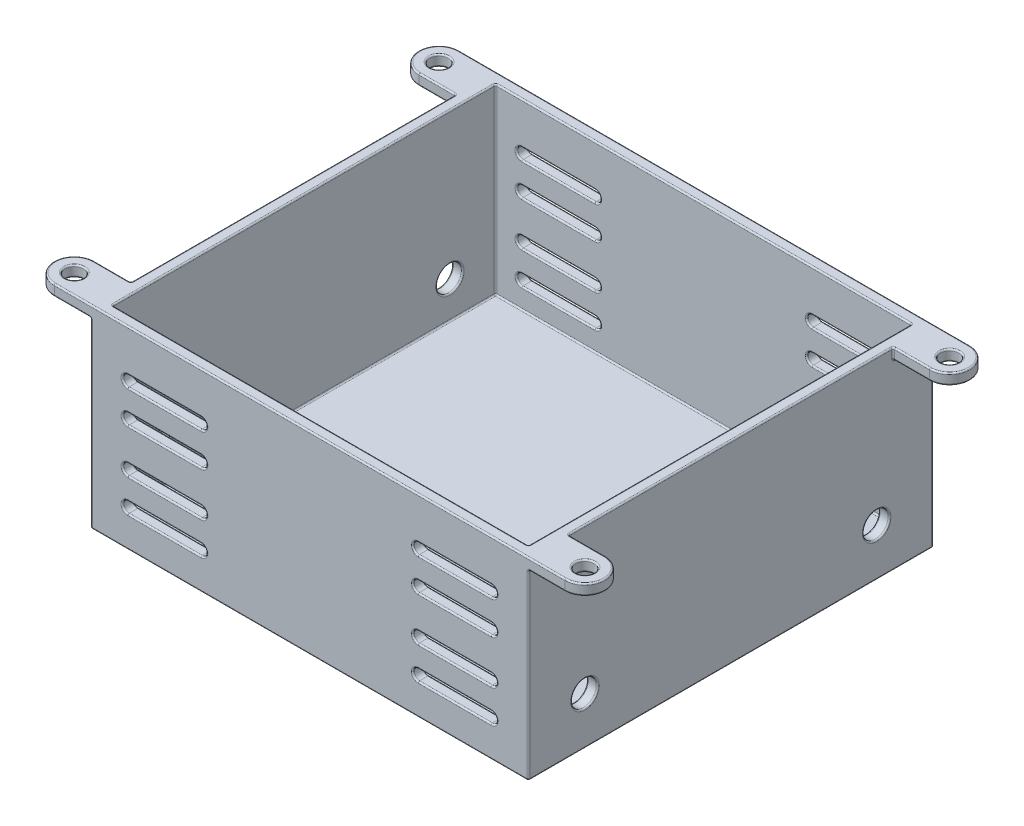
from build123d import *

# Parameters (mm, degrees)
SKETCH9_W                      = 60
SKETCH9_H                      = 55.5
SKETCH9_W_2                    = 57
SKETCH9_H_2                    = 52.5
BOSS_EXTRUDE6_DEPTH            = 25
SKETCH10_W                     = 60
SKETCH10_H                     = 55.5
BOSS_EXTRUDE7_DEPTH            = 1.5
SKETCH11_R                     = 1.25
BOSS_EXTRUDE8_DEPTH            = 1.5
CUT_EXTRUDE1_REACH             = 29.75
CUT_EXTRUDE1_DIRECTION_2_REACH = 29.75
CUT_EXTRUDE2_REACH             = 39.75
SKETCH13_R                     = 1.75
CUT_EXTRUDE2_DIRECTION_2_REACH = 39.75
FILLET1_R                      = 0.2


with BuildPart() as part:
    # Sketch9 → Boss-Extrude6 (new body)
    with BuildSketch(Plane(origin=(0, 0, 0), x_dir=(1, 0, 0), z_dir=(0, 1, 0))):
        Rectangle(SKETCH9_W, SKETCH9_H)
        Rectangle(SKETCH9_W_2, SKETCH9_H_2, mode=Mode.SUBTRACT)
    extrude(amount=-BOSS_EXTRUDE6_DEPTH)

    # Sketch10 → Boss-Extrude7 (add)
    with BuildSketch(Plane.XZ.offset(25)):
        Rectangle(SKETCH10_W, SKETCH10_H)
    extrude(amount=BOSS_EXTRUDE7_DEPTH)

    # Sketch11 → Boss-Extrude8 (add)
    with BuildSketch(Plane(origin=(0, 0, 0), x_dir=(1, 0, 0), z_dir=(0, 1, 0))):
        with BuildLine():
            Line((35, -27.75), (30, -27.75))
            Line((30, -27.75), (30, -22.25))
            Line((30, -22.25), (35, -22.25))
            ThreePointArc((35, -22.25), (37.75, -25), (35, -27.75))
        make_face()
        with Locations((35, -25)):
            Circle(SKETCH11_R, mode=Mode.SUBTRACT)
        with BuildLine():
            Line((-35, 27.75), (-30, 27.75))
            Line((-30, 27.75), (-30, 22.25))
            Line((-30, 22.25), (-35, 22.25))
            ThreePointArc((-35, 22.25), (-37.75, 25), (-35, 27.75))
        make_face()
        with Locations((-35, 25)):
            Circle(SKETCH11_R, mode=Mode.SUBTRACT)
        with BuildLine():
            Line((-35, -22.25), (-30, -22.25))
            Line((-30, -22.25), (-30, -27.75))
            Line((-30, -27.75), (-35, -27.75))
            ThreePointArc((-35, -27.75), (-37.75, -25), (-35, -22.25))
        make_face()
        with Locations((-35, -25)):
            Circle(SKETCH11_R, mode=Mode.SUBTRACT)
        with BuildLine():
            Line((35, 22.25), (30, 22.25))
            Line((30, 22.25), (30, 27.75))
            Line((30, 27.75), (35, 27.75))
            ThreePointArc((35, 27.75), (37.75, 25), (35, 22.25))
        make_face()
        with Locations((35, 25)):
            Circle(SKETCH11_R, mode=Mode.SUBTRACT)
    extrude(amount=-BOSS_EXTRUDE8_DEPTH)

    # Cut-Extrude1: up to this face of the body (flat: up to its plane)
    cut_extrude1_end = Plane(part.part.faces().sort_by_distance((0, -13.13317757, -27.75))[0])
    # Sketch12 → Cut-Extrude1 (cut, up to the picked face)
    with BuildSketch(Plane.XY, mode=Mode.PRIVATE) as cut_extrude1_sk1:
        with BuildLine():
            Line((-24.896270591, -5.75), (-14.896270591, -5.75))
            ThreePointArc((-14.896270591, -5.75), (-14.146270591, -6.5), (-14.896270591, -7.25))
            Line((-14.896270591, -7.25), (-24.896270591, -7.25))
            ThreePointArc((-24.896270591, -7.25), (-25.646270591, -6.5), (-24.896270591, -5.75))
        make_face()
    cut_extrude1_tool1 = split(extrude(cut_extrude1_sk1.sketch, amount=-CUT_EXTRUDE1_REACH, mode=Mode.PRIVATE), bisect_by=cut_extrude1_end, keep=Keep.BOTH, mode=Mode.PRIVATE)
    add(cut_extrude1_tool1.solids().sort_by_distance((-19.896271, -6.5, 0))[0], mode=Mode.SUBTRACT)
    # Sketch12 → Cut-Extrude1 (cut, up to the picked face)
    with BuildSketch(Plane.XY, mode=Mode.PRIVATE) as cut_extrude1_sk2:
        with BuildLine():
            Line((-24.896270591, -10.25), (-14.896270591, -10.25))
            ThreePointArc((-14.896270591, -10.25), (-14.146270591, -11), (-14.896270591, -11.75))
            Line((-14.896270591, -11.75), (-24.896270591, -11.75))
            ThreePointArc((-24.896270591, -11.75), (-25.646270591, -11), (-24.896270591, -10.25))
        make_face()
    cut_extrude1_tool2 = split(extrude(cut_extrude1_sk2.sketch, amount=-CUT_EXTRUDE1_REACH, mode=Mode.PRIVATE), bisect_by=cut_extrude1_end, keep=Keep.BOTH, mode=Mode.PRIVATE)
    add(cut_extrude1_tool2.solids().sort_by_distance((-19.896271, -11, 0))[0], mode=Mode.SUBTRACT)
    # Sketch12 → Cut-Extrude1 (cut, up to the picked face)
    with BuildSketch(Plane.XY, mode=Mode.PRIVATE) as cut_extrude1_sk3:
        with BuildLine():
            Line((-24.896270591, -17.75), (-14.896270591, -17.75))
            ThreePointArc((-14.896270591, -17.75), (-14.146270591, -17), (-14.896270591, -16.25))
            Line((-14.896270591, -16.25), (-24.896270591, -16.25))
            ThreePointArc((-24.896270591, -16.25), (-25.646270591, -17), (-24.896270591, -17.75))
        make_face()
    cut_extrude1_tool3 = split(extrude(cut_extrude1_sk3.sketch, amount=-CUT_EXTRUDE1_REACH, mode=Mode.PRIVATE), bisect_by=cut_extrude1_end, keep=Keep.BOTH, mode=Mode.PRIVATE)
    add(cut_extrude1_tool3.solids().sort_by_distance((-19.896271, -17, 0))[0], mode=Mode.SUBTRACT)
    # Sketch12 → Cut-Extrude1 (cut, up to the picked face)
    with BuildSketch(Plane.XY, mode=Mode.PRIVATE) as cut_extrude1_sk4:
        with BuildLine():
            Line((-24.896270591, -22.25), (-14.896270591, -22.25))
            ThreePointArc((-14.896270591, -22.25), (-14.146270591, -21.5), (-14.896270591, -20.75))
            Line((-14.896270591, -20.75), (-24.896270591, -20.75))
            ThreePointArc((-24.896270591, -20.75), (-25.646270591, -21.5), (-24.896270591, -22.25))
        make_face()
    cut_extrude1_tool4 = split(extrude(cut_extrude1_sk4.sketch, amount=-CUT_EXTRUDE1_REACH, mode=Mode.PRIVATE), bisect_by=cut_extrude1_end, keep=Keep.BOTH, mode=Mode.PRIVATE)
    add(cut_extrude1_tool4.solids().sort_by_distance((-19.896271, -21.5, 0))[0], mode=Mode.SUBTRACT)
    # Sketch12 → Cut-Extrude1 (cut, up to the picked face)
    with BuildSketch(Plane.XY, mode=Mode.PRIVATE) as cut_extrude1_sk5:
        with BuildLine():
            Line((24.896270591, -22.25), (14.896270591, -22.25))
            ThreePointArc((14.896270591, -22.25), (14.146270591, -21.5), (14.896270591, -20.75))
            Line((14.896270591, -20.75), (24.896270591, -20.75))
            ThreePointArc((24.896270591, -20.75), (25.646270591, -21.5), (24.896270591, -22.25))
        make_face()
    cut_extrude1_tool5 = split(extrude(cut_extrude1_sk5.sketch, amount=-CUT_EXTRUDE1_REACH, mode=Mode.PRIVATE), bisect_by=cut_extrude1_end, keep=Keep.BOTH, mode=Mode.PRIVATE)
    add(cut_extrude1_tool5.solids().sort_by_distance((19.896271, -21.5, 0))[0], mode=Mode.SUBTRACT)
    # Sketch12 → Cut-Extrude1 (cut, up to the picked face)
    with BuildSketch(Plane.XY, mode=Mode.PRIVATE) as cut_extrude1_sk6:
        with BuildLine():
            Line((24.896270591, -17.75), (14.896270591, -17.75))
            ThreePointArc((14.896270591, -17.75), (14.146270591, -17), (14.896270591, -16.25))
            Line((14.896270591, -16.25), (24.896270591, -16.25))
            ThreePointArc((24.896270591, -16.25), (25.646270591, -17), (24.896270591, -17.75))
        make_face()
    cut_extrude1_tool6 = split(extrude(cut_extrude1_sk6.sketch, amount=-CUT_EXTRUDE1_REACH, mode=Mode.PRIVATE), bisect_by=cut_extrude1_end, keep=Keep.BOTH, mode=Mode.PRIVATE)
    add(cut_extrude1_tool6.solids().sort_by_distance((19.896271, -17, 0))[0], mode=Mode.SUBTRACT)
    # Sketch12 → Cut-Extrude1 (cut, up to the picked face)
    with BuildSketch(Plane.XY, mode=Mode.PRIVATE) as cut_extrude1_sk7:
        with BuildLine():
            Line((24.896270591, -10.25), (14.896270591, -10.25))
            ThreePointArc((14.896270591, -10.25), (14.146270591, -11), (14.896270591, -11.75))
            Line((14.896270591, -11.75), (24.896270591, -11.75))
            ThreePointArc((24.896270591, -11.75), (25.646270591, -11), (24.896270591, -10.25))
        make_face()
    cut_extrude1_tool7 = split(extrude(cut_extrude1_sk7.sketch, amount=-CUT_EXTRUDE1_REACH, mode=Mode.PRIVATE), bisect_by=cut_extrude1_end, keep=Keep.BOTH, mode=Mode.PRIVATE)
    add(cut_extrude1_tool7.solids().sort_by_distance((19.896271, -11, 0))[0], mode=Mode.SUBTRACT)
    # Sketch12 → Cut-Extrude1 (cut, up to the picked face)
    with BuildSketch(Plane.XY, mode=Mode.PRIVATE) as cut_extrude1_sk8:
        with BuildLine():
            Line((24.896270591, -5.75), (14.896270591, -5.75))
            ThreePointArc((14.896270591, -5.75), (14.146270591, -6.5), (14.896270591, -7.25))
            Line((14.896270591, -7.25), (24.896270591, -7.25))
            ThreePointArc((24.896270591, -7.25), (25.646270591, -6.5), (24.896270591, -5.75))
        make_face()
    cut_extrude1_tool8 = split(extrude(cut_extrude1_sk8.sketch, amount=-CUT_EXTRUDE1_REACH, mode=Mode.PRIVATE), bisect_by=cut_extrude1_end, keep=Keep.BOTH, mode=Mode.PRIVATE)
    add(cut_extrude1_tool8.solids().sort_by_distance((19.896271, -6.5, 0))[0], mode=Mode.SUBTRACT)

    # Cut-Extrude1 direction 2: up to this face of the body (flat: up to its plane)
    cut_extrude1_direction_2_end = Plane(part.part.faces().sort_by_distance((0, -13.13317757, 27.75))[0])
    # Sketch12 → Cut-Extrude1 direction 2 (cut, up to the picked face)
    with BuildSketch(Plane.XY, mode=Mode.PRIVATE) as cut_extrude1_direction_2_sk1:
        with BuildLine():
            Line((-24.896270591, -5.75), (-14.896270591, -5.75))
            ThreePointArc((-14.896270591, -5.75), (-14.146270591, -6.5), (-14.896270591, -7.25))
            Line((-14.896270591, -7.25), (-24.896270591, -7.25))
            ThreePointArc((-24.896270591, -7.25), (-25.646270591, -6.5), (-24.896270591, -5.75))
        make_face()
    cut_extrude1_direction_2_tool1 = split(extrude(cut_extrude1_direction_2_sk1.sketch, amount=CUT_EXTRUDE1_DIRECTION_2_REACH, mode=Mode.PRIVATE), bisect_by=cut_extrude1_direction_2_end, keep=Keep.BOTH, mode=Mode.PRIVATE)
    add(cut_extrude1_direction_2_tool1.solids().sort_by_distance((-19.896271, -6.5, 0))[0], mode=Mode.SUBTRACT)
    # Sketch12 → Cut-Extrude1 direction 2 (cut, up to the picked face)
    with BuildSketch(Plane.XY, mode=Mode.PRIVATE) as cut_extrude1_direction_2_sk2:
        with BuildLine():
            Line((-24.896270591, -10.25), (-14.896270591, -10.25))
            ThreePointArc((-14.896270591, -10.25), (-14.146270591, -11), (-14.896270591, -11.75))
            Line((-14.896270591, -11.75), (-24.896270591, -11.75))
            ThreePointArc((-24.896270591, -11.75), (-25.646270591, -11), (-24.896270591, -10.25))
        make_face()
    cut_extrude1_direction_2_tool2 = split(extrude(cut_extrude1_direction_2_sk2.sketch, amount=CUT_EXTRUDE1_DIRECTION_2_REACH, mode=Mode.PRIVATE), bisect_by=cut_extrude1_direction_2_end, keep=Keep.BOTH, mode=Mode.PRIVATE)
    add(cut_extrude1_direction_2_tool2.solids().sort_by_distance((-19.896271, -11, 0))[0], mode=Mode.SUBTRACT)
    # Sketch12 → Cut-Extrude1 direction 2 (cut, up to the picked face)
    with BuildSketch(Plane.XY, mode=Mode.PRIVATE) as cut_extrude1_direction_2_sk3:
        with BuildLine():
            Line((-24.896270591, -17.75), (-14.896270591, -17.75))
            ThreePointArc((-14.896270591, -17.75), (-14.146270591, -17), (-14.896270591, -16.25))
            Line((-14.896270591, -16.25), (-24.896270591, -16.25))
            ThreePointArc((-24.896270591, -16.25), (-25.646270591, -17), (-24.896270591, -17.75))
        make_face()
    cut_extrude1_direction_2_tool3 = split(extrude(cut_extrude1_direction_2_sk3.sketch, amount=CUT_EXTRUDE1_DIRECTION_2_REACH, mode=Mode.PRIVATE), bisect_by=cut_extrude1_direction_2_end, keep=Keep.BOTH, mode=Mode.PRIVATE)
    add(cut_extrude1_direction_2_tool3.solids().sort_by_distance((-19.896271, -17, 0))[0], mode=Mode.SUBTRACT)
    # Sketch12 → Cut-Extrude1 direction 2 (cut, up to the picked face)
    with BuildSketch(Plane.XY, mode=Mode.PRIVATE) as cut_extrude1_direction_2_sk4:
        with BuildLine():
            Line((-24.896270591, -22.25), (-14.896270591, -22.25))
            ThreePointArc((-14.896270591, -22.25), (-14.146270591, -21.5), (-14.896270591, -20.75))
            Line((-14.896270591, -20.75), (-24.896270591, -20.75))
            ThreePointArc((-24.896270591, -20.75), (-25.646270591, -21.5), (-24.896270591, -22.25))
        make_face()
    cut_extrude1_direction_2_tool4 = split(extrude(cut_extrude1_direction_2_sk4.sketch, amount=CUT_EXTRUDE1_DIRECTION_2_REACH, mode=Mode.PRIVATE), bisect_by=cut_extrude1_direction_2_end, keep=Keep.BOTH, mode=Mode.PRIVATE)
    add(cut_extrude1_direction_2_tool4.solids().sort_by_distance((-19.896271, -21.5, 0))[0], mode=Mode.SUBTRACT)
    # Sketch12 → Cut-Extrude1 direction 2 (cut, up to the picked face)
    with BuildSketch(Plane.XY, mode=Mode.PRIVATE) as cut_extrude1_direction_2_sk5:
        with BuildLine():
            Line((24.896270591, -22.25), (14.896270591, -22.25))
            ThreePointArc((14.896270591, -22.25), (14.146270591, -21.5), (14.896270591, -20.75))
            Line((14.896270591, -20.75), (24.896270591, -20.75))
            ThreePointArc((24.896270591, -20.75), (25.646270591, -21.5), (24.896270591, -22.25))
        make_face()
    cut_extrude1_direction_2_tool5 = split(extrude(cut_extrude1_direction_2_sk5.sketch, amount=CUT_EXTRUDE1_DIRECTION_2_REACH, mode=Mode.PRIVATE), bisect_by=cut_extrude1_direction_2_end, keep=Keep.BOTH, mode=Mode.PRIVATE)
    add(cut_extrude1_direction_2_tool5.solids().sort_by_distance((19.896271, -21.5, 0))[0], mode=Mode.SUBTRACT)
    # Sketch12 → Cut-Extrude1 direction 2 (cut, up to the picked face)
    with BuildSketch(Plane.XY, mode=Mode.PRIVATE) as cut_extrude1_direction_2_sk6:
        with BuildLine():
            Line((24.896270591, -17.75), (14.896270591, -17.75))
            ThreePointArc((14.896270591, -17.75), (14.146270591, -17), (14.896270591, -16.25))
            Line((14.896270591, -16.25), (24.896270591, -16.25))
            ThreePointArc((24.896270591, -16.25), (25.646270591, -17), (24.896270591, -17.75))
        make_face()
    cut_extrude1_direction_2_tool6 = split(extrude(cut_extrude1_direction_2_sk6.sketch, amount=CUT_EXTRUDE1_DIRECTION_2_REACH, mode=Mode.PRIVATE), bisect_by=cut_extrude1_direction_2_end, keep=Keep.BOTH, mode=Mode.PRIVATE)
    add(cut_extrude1_direction_2_tool6.solids().sort_by_distance((19.896271, -17, 0))[0], mode=Mode.SUBTRACT)
    # Sketch12 → Cut-Extrude1 direction 2 (cut, up to the picked face)
    with BuildSketch(Plane.XY, mode=Mode.PRIVATE) as cut_extrude1_direction_2_sk7:
        with BuildLine():
            Line((24.896270591, -10.25), (14.896270591, -10.25))
            ThreePointArc((14.896270591, -10.25), (14.146270591, -11), (14.896270591, -11.75))
            Line((14.896270591, -11.75), (24.896270591, -11.75))
            ThreePointArc((24.896270591, -11.75), (25.646270591, -11), (24.896270591, -10.25))
        make_face()
    cut_extrude1_direction_2_tool7 = split(extrude(cut_extrude1_direction_2_sk7.sketch, amount=CUT_EXTRUDE1_DIRECTION_2_REACH, mode=Mode.PRIVATE), bisect_by=cut_extrude1_direction_2_end, keep=Keep.BOTH, mode=Mode.PRIVATE)
    add(cut_extrude1_direction_2_tool7.solids().sort_by_distance((19.896271, -11, 0))[0], mode=Mode.SUBTRACT)
    # Sketch12 → Cut-Extrude1 direction 2 (cut, up to the picked face)
    with BuildSketch(Plane.XY, mode=Mode.PRIVATE) as cut_extrude1_direction_2_sk8:
        with BuildLine():
            Line((24.896270591, -5.75), (14.896270591, -5.75))
            ThreePointArc((14.896270591, -5.75), (14.146270591, -6.5), (14.896270591, -7.25))
            Line((14.896270591, -7.25), (24.896270591, -7.25))
            ThreePointArc((24.896270591, -7.25), (25.646270591, -6.5), (24.896270591, -5.75))
        make_face()
    cut_extrude1_direction_2_tool8 = split(extrude(cut_extrude1_direction_2_sk8.sketch, amount=CUT_EXTRUDE1_DIRECTION_2_REACH, mode=Mode.PRIVATE), bisect_by=cut_extrude1_direction_2_end, keep=Keep.BOTH, mode=Mode.PRIVATE)
    add(cut_extrude1_direction_2_tool8.solids().sort_by_distance((19.896271, -6.5, 0))[0], mode=Mode.SUBTRACT)

    # Cut-Extrude2: up to this face of the body (flat: up to its plane)
    cut_extrude2_end = Plane(part.part.faces().sort_by_distance((30, -13.391825683, 0))[0])
    # Sketch13 → Cut-Extrude2 (cut, up to the picked face)
    with BuildSketch(Plane(origin=(0, 0, 0), x_dir=(0, 0, -1), z_dir=(1, 0, 0)), mode=Mode.PRIVATE) as cut_extrude2_sk1:
        with Locations((-20, -20)):
            Circle(SKETCH13_R)
    cut_extrude2_tool1 = split(extrude(cut_extrude2_sk1.sketch, amount=CUT_EXTRUDE2_REACH, mode=Mode.PRIVATE), bisect_by=cut_extrude2_end, keep=Keep.BOTH, mode=Mode.PRIVATE)
    add(cut_extrude2_tool1.solids().sort_by_distance((0, -20, 20))[0], mode=Mode.SUBTRACT)
    # Sketch13 → Cut-Extrude2 (cut, up to the picked face)
    with BuildSketch(Plane(origin=(0, 0, 0), x_dir=(0, 0, -1), z_dir=(1, 0, 0)), mode=Mode.PRIVATE) as cut_extrude2_sk2:
        with Locations((20, -20)):
            Circle(SKETCH13_R)
    cut_extrude2_tool2 = split(extrude(cut_extrude2_sk2.sketch, amount=CUT_EXTRUDE2_REACH, mode=Mode.PRIVATE), bisect_by=cut_extrude2_end, keep=Keep.BOTH, mode=Mode.PRIVATE)
    add(cut_extrude2_tool2.solids().sort_by_distance((0, -20, -20))[0], mode=Mode.SUBTRACT)

    # Cut-Extrude2 direction 2: up to this face of the body (flat: up to its plane)
    cut_extrude2_direction_2_end = Plane(part.part.faces().sort_by_distance((-30, -13.391825683, 0))[0])
    # Sketch13 → Cut-Extrude2 direction 2 (cut, up to the picked face)
    with BuildSketch(Plane(origin=(0, 0, 0), x_dir=(0, 0, -1), z_dir=(1, 0, 0)), mode=Mode.PRIVATE) as cut_extrude2_direction_2_sk1:
        with Locations((-20, -20)):
            Circle(SKETCH13_R)
    cut_extrude2_direction_2_tool1 = split(extrude(cut_extrude2_direction_2_sk1.sketch, amount=-CUT_EXTRUDE2_DIRECTION_2_REACH, mode=Mode.PRIVATE), bisect_by=cut_extrude2_direction_2_end, keep=Keep.BOTH, mode=Mode.PRIVATE)
    add(cut_extrude2_direction_2_tool1.solids().sort_by_distance((0, -20, 20))[0], mode=Mode.SUBTRACT)
    # Sketch13 → Cut-Extrude2 direction 2 (cut, up to the picked face)
    with BuildSketch(Plane(origin=(0, 0, 0), x_dir=(0, 0, -1), z_dir=(1, 0, 0)), mode=Mode.PRIVATE) as cut_extrude2_direction_2_sk2:
        with Locations((20, -20)):
            Circle(SKETCH13_R)
    cut_extrude2_direction_2_tool2 = split(extrude(cut_extrude2_direction_2_sk2.sketch, amount=-CUT_EXTRUDE2_DIRECTION_2_REACH, mode=Mode.PRIVATE), bisect_by=cut_extrude2_direction_2_end, keep=Keep.BOTH, mode=Mode.PRIVATE)
    add(cut_extrude2_direction_2_tool2.solids().sort_by_distance((0, -20, -20))[0], mode=Mode.SUBTRACT)

    # Fillet1
    fillet1_edges = [part.edges().sort_by_distance(p)[0] for p in [
        (-25.646270591, -6.5, -26.25),
        (-19.896270591, -5.75, -26.25),
        (-14.146270591, -6.5, -26.25),
        (-19.896270591, -7.25, -26.25),
        (25.646270591, -6.5, -26.25),
        (19.896270591, -7.25, -26.25),
        (14.146270591, -6.5, -26.25),
        (19.896270591, -5.75, -26.25),
        (25.646270591, -11, -26.25),
        (19.896270591, -11.75, -26.25),
        (14.146270591, -11, -26.25),
        (19.896270591, -10.25, -26.25),
        (25.646270591, -17, -26.25),
        (19.896270591, -17.75, -26.25),
        (14.146270591, -17, -26.25),
        (19.896270591, -16.25, -26.25),
        (25.646270591, -21.5, -26.25),
        (19.896270591, -22.25, -26.25),
        (14.146270591, -21.5, -26.25),
        (19.896270591, -20.75, -26.25),
        (-25.646270591, -21.5, -26.25),
        (-19.896270591, -20.75, -26.25),
        (-14.146270591, -21.5, -26.25),
        (-19.896270591, -22.25, -26.25),
        (-25.646270591, -17, -26.25),
        (-19.896270591, -16.25, -26.25),
        (-14.146270591, -17, -26.25),
        (-19.896270591, -17.75, -26.25),
        (-25.646270591, -11, -26.25),
        (-19.896270591, -10.25, -26.25),
        (-14.146270591, -11, -26.25),
        (-19.896270591, -11.75, -26.25),
        (28.5, -25, 0),
        (28.5, -12.5, -26.25),
        (0, -25, 26.25),
        (28.5, -12.5, 26.25),
        (-28.5, -25, 0),
        (-28.5, -12.5, 26.25),
        (0, -25, -26.25),
        (-28.5, -12.5, -26.25),
        (28.5, 0, 0),
        (-19.896270591, -11.75, 26.25),
        (-19.896270591, -11.75, -27.75),
        (-14.146270591, -11, 26.25),
        (-14.146270591, -11, -27.75),
        (-19.896270591, -10.25, 26.25),
        (0, 0, -26.25),
        (-19.896270591, -10.25, -27.75),
        (-25.646270591, -11, 26.25),
        (-25.646270591, -11, -27.75),
        (-19.896270591, -10.25, 27.75),
        (-25.646270591, -11, 27.75),
        (-19.896270591, -11.75, 27.75),
        (-14.146270591, -11, 27.75),
        (-28.5, 0, 0),
        (0, 0, 26.25),
        (-19.896270591, -17.75, 26.25),
        (-19.896270591, -17.75, -27.75),
        (-14.146270591, -17, 26.25),
        (-14.146270591, -17, -27.75),
        (-19.896270591, -16.25, 26.25),
        (-19.896270591, -16.25, -27.75),
        (-25.646270591, -17, 26.25),
        (-25.646270591, -17, -27.75),
        (-19.896270591, -16.25, 27.75),
        (-25.646270591, -17, 27.75),
        (-19.896270591, -17.75, 27.75),
        (-14.146270591, -17, 27.75),
        (-19.896270591, -22.25, 26.25),
        (-19.896270591, -22.25, -27.75),
        (-14.146270591, -21.5, 26.25),
        (-14.146270591, -21.5, -27.75),
        (-19.896270591, -20.75, 26.25),
        (-19.896270591, -20.75, -27.75),
        (-25.646270591, -21.5, 26.25),
        (-25.646270591, -21.5, -27.75),
        (-19.896270591, -20.75, 27.75),
        (-25.646270591, -21.5, 27.75),
        (-19.896270591, -22.25, 27.75),
        (-14.146270591, -21.5, 27.75),
        (19.896270591, -20.75, 26.25),
        (19.896270591, -20.75, -27.75),
        (14.146270591, -21.5, 26.25),
        (14.146270591, -21.5, -27.75),
        (19.896270591, -22.25, 26.25),
        (19.896270591, -22.25, -27.75),
        (25.646270591, -21.5, 26.25),
        (25.646270591, -21.5, -27.75),
        (19.896270591, -22.25, 27.75),
        (25.646270591, -21.5, 27.75),
        (19.896270591, -20.75, 27.75),
        (14.146270591, -21.5, 27.75),
        (19.896270591, -16.25, 26.25),
        (19.896270591, -16.25, -27.75),
        (14.146270591, -17, 26.25),
        (14.146270591, -17, -27.75),
        (19.896270591, -17.75, 26.25),
        (19.896270591, -17.75, -27.75),
        (25.646270591, -17, 26.25),
        (25.646270591, -17, -27.75),
        (19.896270591, -17.75, 27.75),
        (25.646270591, -17, 27.75),
        (19.896270591, -16.25, 27.75),
        (14.146270591, -17, 27.75),
        (19.896270591, -10.25, 26.25),
        (19.896270591, -10.25, -27.75),
        (14.146270591, -11, 26.25),
        (14.146270591, -11, -27.75),
        (19.896270591, -11.75, 26.25),
        (19.896270591, -11.75, -27.75),
        (25.646270591, -11, 26.25),
        (25.646270591, -11, -27.75),
        (19.896270591, -11.75, 27.75),
        (25.646270591, -11, 27.75),
        (19.896270591, -10.25, 27.75),
        (14.146270591, -11, 27.75),
        (19.896270591, -5.75, 26.25),
        (19.896270591, -5.75, -27.75),
        (14.146270591, -6.5, 26.25),
        (14.146270591, -6.5, -27.75),
        (19.896270591, -7.25, 26.25),
        (19.896270591, -7.25, -27.75),
        (25.646270591, -6.5, 26.25),
        (25.646270591, -6.5, -27.75),
        (19.896270591, -7.25, 27.75),
        (25.646270591, -6.5, 27.75),
        (19.896270591, -5.75, 27.75),
        (14.146270591, -6.5, 27.75),
        (-19.896270591, -7.25, 26.25),
        (-19.896270591, -7.25, -27.75),
        (-14.146270591, -6.5, 26.25),
        (-14.146270591, -6.5, -27.75),
        (-19.896270591, -5.75, 26.25),
        (-19.896270591, -5.75, -27.75),
        (-25.646270591, -6.5, 26.25),
        (-25.646270591, -6.5, -27.75),
        (-19.896270591, -5.75, 27.75),
        (-25.646270591, -6.5, 27.75),
        (-19.896270591, -7.25, 27.75),
        (-14.146270591, -6.5, 27.75),
        (0, -26.5, 27.75),
        (-30, -26.5, 0),
        (0, -26.5, -27.75),
        (-30, -20, 21.75),
        (28.5, -20, 21.75),
        (-28.5, -20, 21.75),
        (30, -26.5, 0),
        (30, -20, 21.75),
        (-30, -20, -18.25),
        (28.5, -20, -18.25),
        (-28.5, -20, -18.25),
        (30, -20, -18.25),
        (-37.75, -1.5, 25),
        (-32.5, -1.5, 22.25),
        (-30, -1.5, 25),
        (-30, -0.75, 22.25),
        (-32.5, -1.5, 27.75),
        (-36.25, -1.5, 25),
        (-37.75, 0, 25),
        (-32.5, 0, 22.25),
        (0, 0, -27.75),
        (-36.25, 0, 25),
        (30, 0, 0),
        (0, 0, 27.75),
        (37.75, -1.5, 25),
        (32.5, -1.5, 27.75),
        (30, -1.5, 25),
        (32.5, -1.5, 22.25),
        (30, -0.75, 22.25),
        (33.75, -1.5, 25),
        (37.75, 0, 25),
        (32.5, 0, 22.25),
        (33.75, 0, 25),
        (37.75, -1.5, -25),
        (32.5, -1.5, -22.25),
        (30, -1.5, -25),
        (30, -0.75, -22.25),
        (32.5, -1.5, -27.75),
        (33.75, -1.5, -25),
        (37.75, 0, -25),
        (32.5, 0, -22.25),
        (33.75, 0, -25),
        (-30, -14, -27.75),
        (30, -14, -27.75),
        (30, -14, 27.75),
        (-30, -14, 27.75),
        (-30, 0, 0),
        (-37.75, -1.5, -25),
        (-32.5, -1.5, -27.75),
        (-30, -1.5, -25),
        (-32.5, -1.5, -22.25),
        (-30, -0.75, -22.25),
        (-36.25, -1.5, -25),
        (-37.75, 0, -25),
        (-32.5, 0, -22.25),
        (-36.25, 0, -25),
    ]]
    fillet(fillet1_edges, radius=FILLET1_R)


solid = part.part
